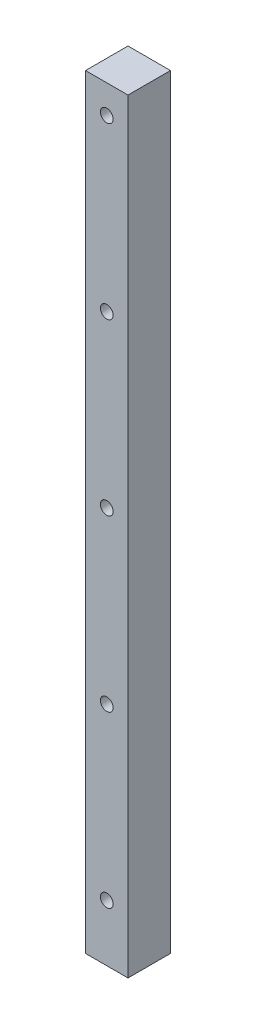
from build123d import *

# Parameters (mm, degrees)
SKETCH_1_W          = 15
SKETCH_1_H          = 15
EXTRUDE_1_DEPTH     = 270
SKETCH_2_R          = 2.25
CUT_EXTRUDE_1_DEPTH = 119


with BuildPart() as part:
    # 草图1 → 凸台-拉伸1 (new body)
    with BuildSketch(Plane(origin=(0, 0, 0), x_dir=(1, 0, 0), z_dir=(0, 1, 0))):
        Rectangle(SKETCH_1_W, SKETCH_1_H)
    extrude(amount=EXTRUDE_1_DEPTH)

    # 草图2 → 切除-拉伸1 (cut)
    with BuildSketch(Plane(origin=(0, 0, -7.5), x_dir=(-1, 0, 0), z_dir=(0, 0, -1))):
        with Locations((0, 20)):
            Circle(SKETCH_2_R)
        with Locations((0, 80)):
            Circle(SKETCH_2_R)
        with Locations((0, 140)):
            Circle(SKETCH_2_R)
        with Locations((0, 200)):
            Circle(SKETCH_2_R)
        with Locations((0, 260)):
            Circle(SKETCH_2_R)
    extrude(amount=-CUT_EXTRUDE_1_DEPTH, mode=Mode.SUBTRACT)


solid = part.part
